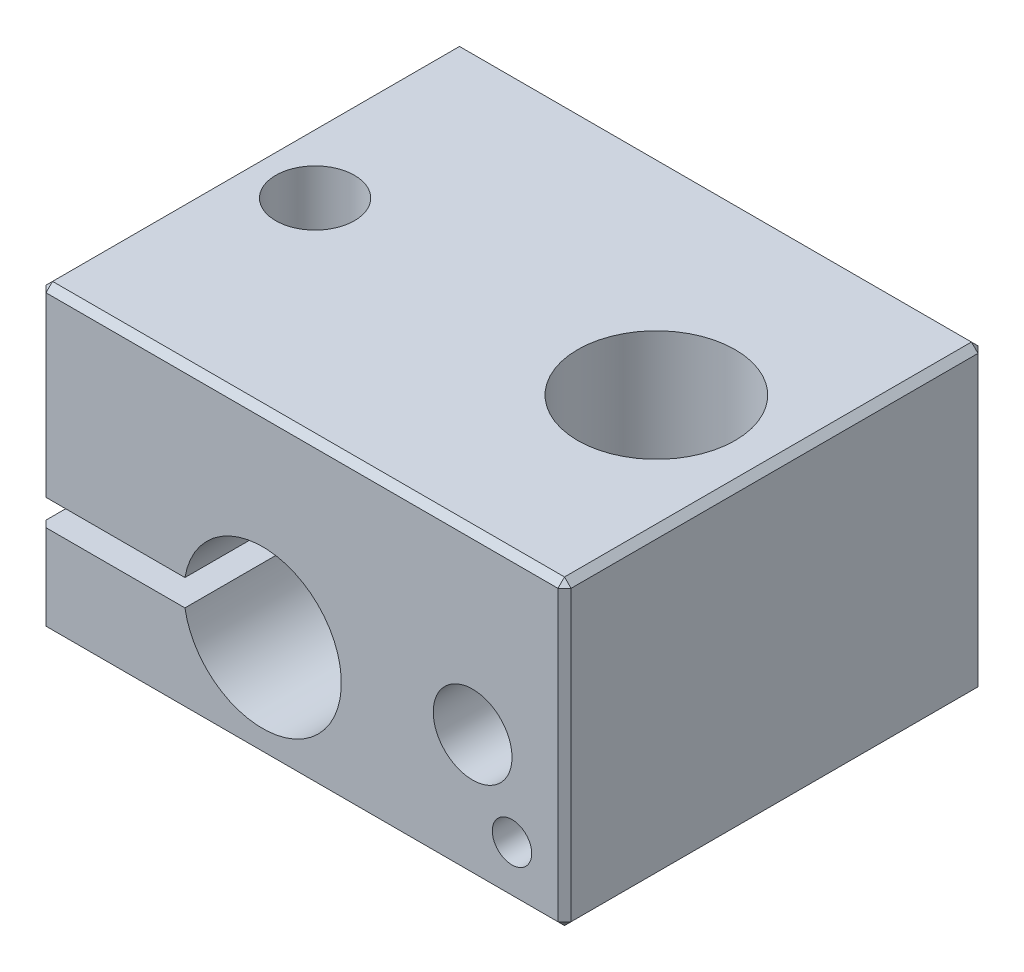
from build123d import *

# Parameters (mm, degrees)
SKETCH1_W                      = 20
SKETCH1_H                      = 16
BOSS_EXTRUDE1_DEPTH            = 11.5
CUT_EXTRUDE1_DEPTH             = 17
SKETCH3_W                      = 3
SKETCH3_H                      = 16
SKETCH4_W                      = 1.5
SKETCH4_H                      = 7
F_6_0_6_DIAMETER_HOLE1_D       = 6
F_6_0_6_DIAMETER_HOLE1_DEPTH   = 11.5
F_3_0_3_DIAMETER_HOLE2_D       = 3
F_3_0_3_DIAMETER_HOLE2_DEPTH   = 3.5
F_3_0_3_DIAMETER_HOLE3_D       = 3
F_3_0_3_DIAMETER_HOLE3_DEPTH   = 3.5
F_1_5_1_5_DIAMETER_HOLE1_D     = 1.5
F_1_5_1_5_DIAMETER_HOLE1_DEPTH = 4.5
CHAMFER1_SIZE                  = 0.25


with BuildPart() as part:
    # Sketch1 → Boss-Extrude1 (new body)
    with BuildSketch(Plane.XZ):
        Rectangle(SKETCH1_W, SKETCH1_H)
    extrude(amount=-BOSS_EXTRUDE1_DEPTH)

    # Sketch2 → Cut-Extrude1 (cut, through all)
    with BuildSketch(Plane(origin=(0, 0, -8), x_dir=(-1, 0, 0), z_dir=(0, 0, -1))):
        with BuildLine():
            Line((10, 3.5), (10, 4.5))
            Line((10, 4.5), (4.458039892, 4.5))
            ThreePointArc((4.458039892, 4.5), (4.5, 4), (4.458039892, 3.5))
            Line((4.458039892, 3.5), (10, 3.5))
        make_face()
    extrude(amount=-CUT_EXTRUDE1_DEPTH, mode=Mode.SUBTRACT)

    # Sketch3 → Cut-Revolve1 (revolve, cut)
    with BuildSketch(Plane(origin=(0, 4, 0), x_dir=(1, 0, 0), z_dir=(0, 1, 0))):
        Rectangle(SKETCH3_W, SKETCH3_H)
    revolve(axis=Axis((-1.5, 4, -8), (0, 0, 1)), mode=Mode.SUBTRACT)

    # Sketch4 → Ø3.0 (3) Diameter Hole1 (revolve, cut)
    with BuildSketch(Plane(origin=(-7.5, 4.5, 0), x_dir=(0, 0, -1), z_dir=(1, 0, 0))):
        with Locations((0.75, 3.5)):
            Rectangle(SKETCH4_W, SKETCH4_H)
    revolve(axis=Axis((-7.5, -1.85, 0), (0, 1, 0)), mode=Mode.SUBTRACT)

    # Ø6.0 (6) Diameter Hole1
    with Locations(Plane(origin=(0, 0, 0), x_dir=(-1, 0, 0), z_dir=(0, -1, 0))):
        with Locations((-5.5, 0)):
            Hole(F_6_0_6_DIAMETER_HOLE1_D / 2, depth=F_6_0_6_DIAMETER_HOLE1_DEPTH)

    # Ø3.0 (3) Diameter Hole2
    with Locations(Plane(origin=(0, 3.5, 0), x_dir=(1, 0, 0), z_dir=(0, 1, 0))):
        with Locations((-7.5, 0)):
            Hole(F_3_0_3_DIAMETER_HOLE2_D / 2, depth=F_3_0_3_DIAMETER_HOLE2_DEPTH)

    # Ø3.0 (3) Diameter Hole3
    with Locations(Plane.XY.offset(8)):
        with Locations((6.5, 4.8)):
            Hole(F_3_0_3_DIAMETER_HOLE3_D / 2, depth=F_3_0_3_DIAMETER_HOLE3_DEPTH)

    # Ø1.5 (1.5) Diameter Hole1
    with Locations(Plane.XY.offset(8)):
        with Locations((8, 2)):
            Hole(F_1_5_1_5_DIAMETER_HOLE1_D / 2, depth=F_1_5_1_5_DIAMETER_HOLE1_DEPTH)

    # Chamfer1
    chamfer1_edges = [part.edges().sort_by_distance(p)[0] for p in [
        (0, 11.5, 8),
        (-10, 11.5, 0),
        (-10, 1.75, 8),
        (-10, 1.75, -8),
        (0, 11.5, -8),
        (-10, 0, 0),
        (0, 0, 8),
        (10, 0, 0),
        (0, 0, -8),
        (10, 11.5, 0),
        (-10, 8, -8),
        (-10, 8, 8),
        (10, 5.75, 8),
        (10, 5.75, -8),
    ]]
    chamfer(chamfer1_edges, length=CHAMFER1_SIZE)


solid = part.part
